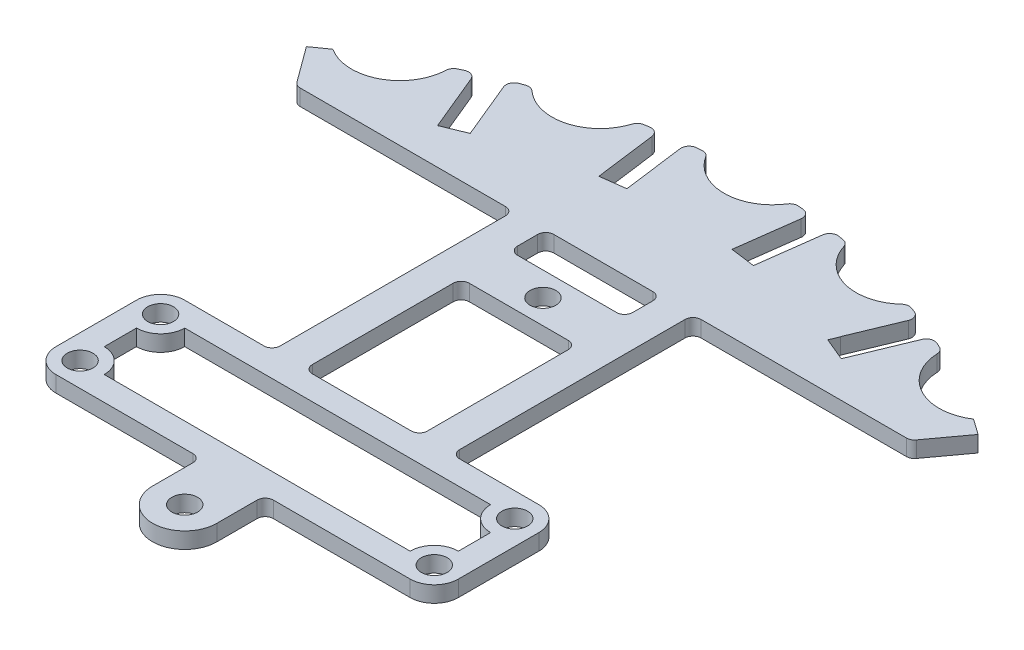
from build123d import *

# Parameters (mm, degrees)
SKETCH1_R           = 1.6
BOSS_EXTRUDE1_DEPTH = 2
SKETCH2_R           = 6
CUT_EXTRUDE1_DEPTH  = 2
SKETCH4_R           = 106.164110188
SKETCH4_R_2         = 70.5
CUT_EXTRUDE3_DEPTH  = 5
SKETCH5_R           = 1.6
SKETCH5_W           = 14.30009681
SKETCH5_H           = 30
CUT_EXTRUDE4_DEPTH  = 5
SKETCH6_R           = 1.6
BOSS_EXTRUDE2_DEPTH = 2
FILLET1_R           = 1
FILLET2_R           = 1
FILLET3_R           = 1
SKETCH7_W           = 14.30009681
SKETCH7_H           = 19
CUT_EXTRUDE5_DEPTH  = 10
SKETCH8_R           = 1.6
BOSS_EXTRUDE3_DEPTH = 2
FILLET4_R           = 1
FILLET5_R           = 1


with BuildPart() as part:
    # Sketch1 → Boss-Extrude1 (new body)
    with BuildSketch(Plane(origin=(0, 0, 0), x_dir=(1, 0, 0), z_dir=(0, 1, 0))):
        with BuildLine():
            Line((-11.150048405, 22), (-16.150048405, 22))
            Line((-16.150048405, 22), (-22, 22))
            ThreePointArc((-22, 22), (-24.121320344, 21.121320344), (-25, 19))
            Line((-25, 19), (-25, 9))
            ThreePointArc((-25, 9), (-24.121320344, 6.878679656), (-22, 6))
            Line((-22, 6), (-4, 6))
            Line((-4, 6), (-4, 0))
            ThreePointArc((-4, 0), (0, -4), (4, 0))
            Line((4, 0), (4, 6))
            Line((4, 6), (22, 6))
            ThreePointArc((22, 6), (24.121320344, 6.878679656), (25, 9))
            Line((25, 9), (25, 19))
            ThreePointArc((25, 19), (24.121320344, 21.121320344), (22, 22))
            Line((22, 22), (16.150048405, 22))
            Line((16.150048405, 22), (11.150048405, 22))
            Line((11.150048405, 22), (11.150048405, 52))
            Line((11.150048405, 52), (38.172841685, 52))
            Line((38.172841685, 52), (43.198616574, 58.846236295))
            ThreePointArc((43.198616574, 58.846236295), (41.979173366, 59.722265559), (40.741970589, 60.57302892))
            ThreePointArc((40.741970589, 60.57302892), (34, 58.889727457), (32.086796535, 65.57009599))
            ThreePointArc((32.086796535, 65.57009599), (30.731412463, 66.216163344), (29.363027262, 66.834217509))
            Line((29.363027262, 66.834217509), (28.896755531, 65.707960895))
            Line((28.896755531, 65.707960895), (25.53786679, 57.594729029))
            Line((25.53786679, 57.594729029), (24.092095177, 58.193280392))
            Line((24.092095177, 58.193280392), (22.646323564, 58.791831755))
            Line((22.646323564, 58.791831755), (25.899863987, 66.650599899))
            Line((25.899863987, 66.650599899), (26.471484036, 68.031320235))
            ThreePointArc((26.471484036, 68.031320235), (25.079087969, 68.556832968), (23.676268101, 69.053850934))
            ThreePointArc((23.676268101, 69.053850934), (17.599695067, 65.682956188), (14.022675824, 71.640523189))
            ThreePointArc((14.022675824, 71.640523189), (12.546260809, 71.91377712), (11.064538014, 72.156607449))
            Line((11.064538014, 72.156607449), (10.905809079, 70.950941483))
            Line((10.905809079, 70.950941483), (9.759276092, 62.242158835))
            Line((9.759276092, 62.242158835), (6.682719292, 62.647195222))
            Line((6.682719292, 62.647195222), (7.829252278, 71.35597787))
            Line((7.829252278, 71.35597787), (7.987981214, 72.561643836))
            ThreePointArc((7.987981214, 72.561643836), (6.493897785, 72.710585829), (4.99706707, 72.828767123))
            ThreePointArc((4.99706707, 72.828767123), (0, 68), (-4.99706707, 72.828767123))
            ThreePointArc((-4.99706707, 72.828767123), (-6.493897785, 72.710585829), (-7.987981214, 72.561643836))
            Line((-7.987981214, 72.561643836), (-7.829252278, 71.35597787))
            Line((-7.829252278, 71.35597787), (-6.682719292, 62.647195222))
            Line((-6.682719292, 62.647195222), (-8.220997692, 62.444677029))
            Line((-8.220997692, 62.444677029), (-9.759276092, 62.242158835))
            Line((-9.759276092, 62.242158835), (-10.905809079, 70.950941483))
            Line((-10.905809079, 70.950941483), (-11.064538014, 72.156607449))
            ThreePointArc((-11.064538014, 72.156607449), (-12.546260809, 71.91377712), (-14.022675824, 71.640523189))
            ThreePointArc((-14.022675824, 71.640523189), (-17.599695067, 65.682956188), (-23.676268101, 69.053850934))
            ThreePointArc((-23.676268101, 69.053850934), (-25.091507977, 68.552288273), (-26.496132723, 68.021724109))
            Line((-26.496132723, 68.021724109), (-26.030763031, 66.898222286))
            Line((-26.030763031, 66.898222286), (-22.669298399, 58.782928784))
            Line((-22.669298399, 58.782928784), (-24.102745669, 58.189175484))
            Line((-24.102745669, 58.189175484), (-25.536192938, 57.595422184))
            Line((-25.536192938, 57.595422184), (-28.897657569, 65.710715687))
            Line((-28.897657569, 65.710715687), (-29.363027262, 66.834217509))
            ThreePointArc((-29.363027262, 66.834217509), (-30.731412463, 66.216163344), (-32.086796535, 65.57009599))
            ThreePointArc((-32.086796535, 65.57009599), (-34, 58.889727457), (-40.741970589, 60.57302892))
            ThreePointArc((-40.741970589, 60.57302892), (-41.979173366, 59.722265559), (-43.198616574, 58.846236295))
            Line((-43.198616574, 58.846236295), (-38.172841685, 52))
            Line((-38.172841685, 52), (-11.150048405, 52))
            Line((-11.150048405, 52), (-11.150048405, 22))
        make_face()
        Circle(SKETCH1_R, mode=Mode.SUBTRACT)
    extrude(amount=BOSS_EXTRUDE1_DEPTH)

    # Sketch2 → Cut-Extrude1 (cut)
    with BuildSketch(Plane(origin=(0, 2, 0), x_dir=(1, 0, 0), z_dir=(0, 1, 0))):
        with Locations((0, 73)):
            Circle(SKETCH2_R)
        with Locations((-18.893790292, 70.512585319)):
            Circle(SKETCH2_R)
        with Locations((-36.5, 63.219854476)):
            Circle(SKETCH2_R)
        with Locations((18.893790292, 70.512585319)):
            Circle(SKETCH2_R)
        with Locations((36.5, 63.219854476)):
            Circle(SKETCH2_R)
    extrude(amount=-CUT_EXTRUDE1_DEPTH, mode=Mode.SUBTRACT)

    # Sketch4 → Cut-Extrude3 (cut)
    with BuildSketch(Plane(origin=(0, 2, 0), x_dir=(1, 0, 0), z_dir=(0, 1, 0))):
        Circle(SKETCH4_R)
        Circle(SKETCH4_R_2, mode=Mode.SUBTRACT)
        Polygon((-25.536192938, 57.595422184), (-25.076972819, 56.486766745), (-22.210078281, 57.674273345), (-22.669298399, 58.782928784), align=None)
        Polygon((-9.759276092, 62.242158835), (-9.602644661, 61.052425001), (-6.526087861, 61.457461388), (-6.682719292, 62.647195222), align=None)
        Polygon((9.759276092, 62.242158835), (6.682719292, 62.647195222), (6.526087861, 61.457461388), (9.602644661, 61.052425001), align=None)
        Polygon((22.210078281, 57.674273345), (25.076972819, 56.486766745), (25.536192938, 57.595422184), (22.669298399, 58.782928784), align=None)
    extrude(amount=-CUT_EXTRUDE3_DEPTH, mode=Mode.SUBTRACT)

    # Sketch5 → Cut-Extrude4 (cut)
    with BuildSketch(Plane(origin=(0, 2, 0), x_dir=(1, 0, 0), z_dir=(0, 1, 0))):
        with Locations((22, 19)):
            Circle(SKETCH5_R)
        with Locations((-22, 19)):
            Circle(SKETCH5_R)
        with Locations((-22, 9)):
            Circle(SKETCH5_R)
        with Locations((22, 9)):
            Circle(SKETCH5_R)
        with BuildLine():
            Line((-22, 16), (-22, 12))
            ThreePointArc((-22, 12), (-19.878679656, 11.121320344), (-19, 9))
            Line((-19, 9), (19, 9))
            ThreePointArc((19, 9), (19.878679656, 11.121320344), (22, 12))
            Line((22, 12), (22, 16))
            ThreePointArc((22, 16), (19.878679656, 16.878679656), (19, 19))
            Line((19, 19), (-19, 19))
            ThreePointArc((-19, 19), (-19.878679656, 16.878679656), (-22, 16))
        make_face()
        with Locations((0, 37)):
            Rectangle(SKETCH5_W, SKETCH5_H)
    extrude(amount=-CUT_EXTRUDE4_DEPTH, mode=Mode.SUBTRACT)

    # Sketch6 → Boss-Extrude2 (add)
    with BuildSketch(Plane(origin=(0, 2, 0), x_dir=(1, 0, 0), z_dir=(0, 1, 0))):
        Polygon((0, 44), (-7.150048405, 44), (-7.150048405, 36), (7.150048405, 36), (7.150048405, 44), align=None)
        with Locations((0, 40)):
            Circle(SKETCH6_R, mode=Mode.SUBTRACT)
    extrude(amount=-BOSS_EXTRUDE2_DEPTH)

    # Fillet1
    fillet1_edges = [part.edges().sort_by_distance(p)[0] for p in [
        (-7.150048405, 1, -44),
        (-7.150048405, 1, -36),
        (7.150048405, 1, -36),
        (7.150048405, 1, -44),
    ]]
    fillet(fillet1_edges, radius=FILLET1_R)

    # Fillet2
    fillet2_edges = [part.edges().sort_by_distance(p)[0] for p in [
        (-7.150048405, 1, -22),
        (-7.150048405, 1, -52),
        (7.150048405, 1, -52),
        (7.150048405, 1, -22),
    ]]
    fillet(fillet2_edges, radius=FILLET2_R)

    # Fillet3
    fillet3_edges = [part.edges().sort_by_distance(p)[0] for p in [
        (38.172841685, 1, -52),
        (-38.172841685, 1, -52),
    ]]
    fillet(fillet3_edges, radius=FILLET3_R)

    # Sketch7 → Cut-Extrude5 (cut)
    with BuildSketch(Plane(origin=(0, 2, 0), x_dir=(1, 0, 0), z_dir=(0, 1, 0))):
        with Locations((0, 38.5)):
            Rectangle(SKETCH7_W, SKETCH7_H)
    extrude(amount=-CUT_EXTRUDE5_DEPTH, mode=Mode.SUBTRACT)

    # Sketch8 → Boss-Extrude3 (add)
    with BuildSketch(Plane(origin=(0, 2, 0), x_dir=(1, 0, 0), z_dir=(0, 1, 0))):
        Polygon((7.150048405, 47.5), (7.150048405, 41.5), (-7.150048405, 41.5), (-7.150048405, 47.5), (0, 47.5), align=None)
        with Locations((0, 44.5)):
            Circle(SKETCH8_R, mode=Mode.SUBTRACT)
    extrude(amount=-BOSS_EXTRUDE3_DEPTH)

    # Fillet4
    fillet4_edges = [part.edges().sort_by_distance(p)[0] for p in [
        (7.150048405, 1, -41.5),
        (7.150048405, 1, -47.5),
        (-7.150048405, 1, -47.5),
        (-7.150048405, 1, -41.5),
        (11.150048405, 1, -52),
        (11.150048405, 1, -22),
        (4, 1, -6),
        (-4, 1, -6),
        (-11.150048405, 1, -22),
        (-11.150048405, 1, -52),
    ]]
    fillet(fillet4_edges, radius=FILLET4_R)

    # Fillet5
    fillet5_edges = [part.edges().sort_by_distance(p)[0] for p in [
        (-23.367764748, 1, -66.514641777),
        (-13.020242987, 1, -69.287251876),
        (5.356271403, 1, -70.296232877),
        (-5.356271403, 1, -70.296232877),
        (-7.661589388, 1, -70.082451784),
        (-25.53920031, 1, -65.711484898),
        (-30.509449334, 1, -63.556459163),
        (30.509449334, 1, -63.556459163),
        (28.406509578, 1, -64.523795716),
        (23.367764748, 1, -66.514641777),
        (13.020242987, 1, -69.287251876),
        (10.738146189, 1, -69.677415397),
        (7.661589388, 1, -70.082451784),
        (25.514966352, 1, -65.720898442),
        (-28.406094848, 1, -64.523978299),
        (-10.738146189, 1, -69.677415397),
    ]]
    fillet(fillet5_edges, radius=FILLET5_R)


solid = part.part
